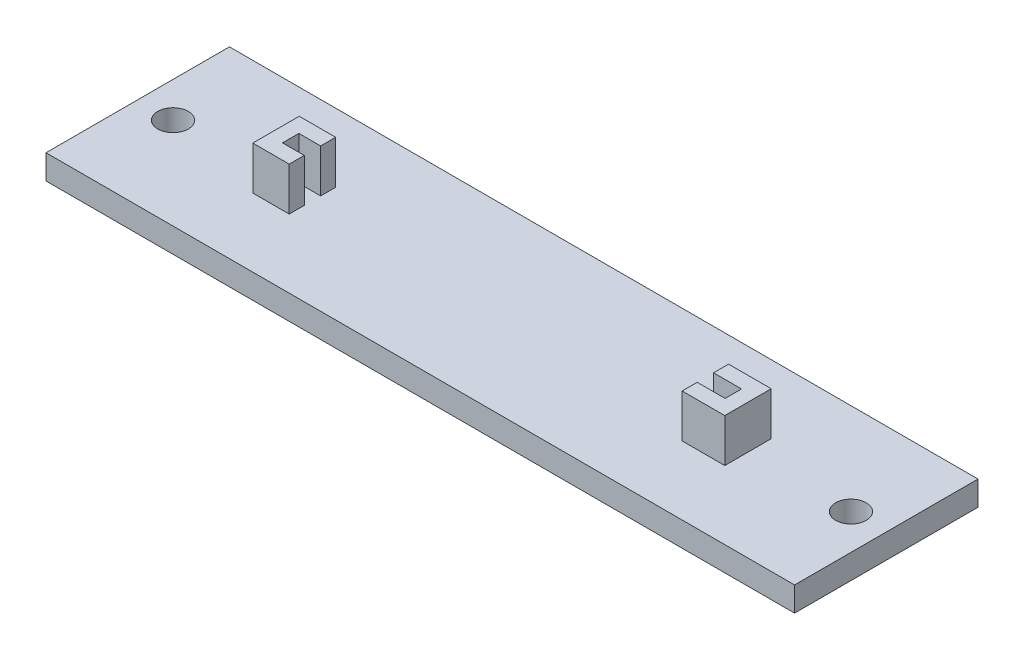
from build123d import *

# Parameters (mm, degrees)
SKETCH1_W           = 77.75
SKETCH1_H           = 19.05
BOSS_EXTRUDE1_DEPTH = 2.54
SKETCH2_R           = 1.5875
CUT_EXTRUDE1_DEPTH  = 3.54
SKETCH3_W           = 49.022
SKETCH3_H           = 4.826
BOSS_EXTRUDE2_DEPTH = 4.4958
SKETCH4_W           = 45.974
SKETCH4_H           = 1.7018
CUT_EXTRUDE2_DEPTH  = 4.4958
SKETCH6_W           = 40.810788913
SKETCH6_H           = 1.5621
CUT_EXTRUDE3_DEPTH  = 4.4958


with BuildPart() as part:
    # Sketch1 → Boss-Extrude1 (new body)
    with BuildSketch(Plane(origin=(0, 0, 0), x_dir=(1, 0, 0), z_dir=(0, 1, 0))):
        Rectangle(SKETCH1_W, SKETCH1_H)
    extrude(amount=BOSS_EXTRUDE1_DEPTH)

    # Sketch2 → Cut-Extrude1 (cut, through all)
    with BuildSketch(Plane(origin=(0, 2.54, 0), x_dir=(1, 0, 0), z_dir=(0, 1, 0))):
        with Locations((35.2047, 0)):
            Circle(SKETCH2_R)
        with Locations((-35.2047, 0)):
            Circle(SKETCH2_R)
    extrude(amount=-CUT_EXTRUDE1_DEPTH, mode=Mode.SUBTRACT)

    # Sketch3 → Boss-Extrude2 (add)
    with BuildSketch(Plane(origin=(0, 2.54, 0), x_dir=(1, 0, 0), z_dir=(0, 1, 0))):
        Rectangle(SKETCH3_W, SKETCH3_H)
    extrude(amount=BOSS_EXTRUDE2_DEPTH)

    # Sketch4 → Cut-Extrude2 (cut)
    with BuildSketch(Plane(origin=(0, 7.0358, 0), x_dir=(1, 0, 0), z_dir=(0, 1, 0))):
        Rectangle(SKETCH4_W, SKETCH4_H)
    extrude(amount=-CUT_EXTRUDE2_DEPTH, mode=Mode.SUBTRACT)

    # Sketch6 → Cut-Extrude3 (cut)
    with BuildSketch(Plane(origin=(0, 7.0358, 0), x_dir=(1, 0, 0), z_dir=(0, 1, 0))):
        with Locations((-0.321005544, -1.63195)):
            Rectangle(SKETCH6_W, SKETCH6_H)
        with Locations((-0.321005544, 1.63195)):
            Rectangle(SKETCH6_W, SKETCH6_H)
    extrude(amount=-CUT_EXTRUDE3_DEPTH, mode=Mode.SUBTRACT)


solid = part.part
